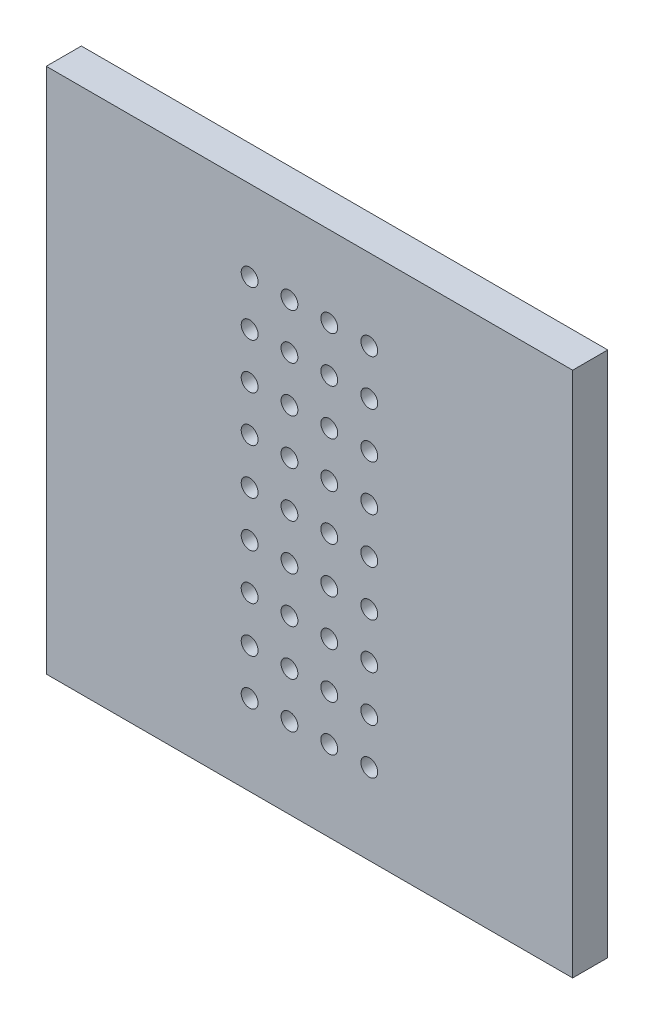
from build123d import *

# Parameters (mm, degrees)
ESQUISSE1_W            = 30
ESQUISSE1_H            = 30
BASE_PLATE_DEPTH       = 2
SKETCH_PERFORATIONS_R  = 0.48
CUT_PERFORATIONS_DEPTH = 10


with BuildPart() as part:
    # Esquisse1 → Base_Plate (new body)
    with BuildSketch(Plane.XY):
        Rectangle(ESQUISSE1_W, ESQUISSE1_H)
    extrude(amount=BASE_PLATE_DEPTH)

    # Sketch_Perforations → Cut_Perforations (cut)
    with BuildSketch(Plane.XY.offset(2)):
        with Locations((-3.41, -10.4)):
            Circle(SKETCH_PERFORATIONS_R)
        with Locations((-3.41, -7.8)):
            Circle(SKETCH_PERFORATIONS_R)
        with Locations((-3.41, -5.2)):
            Circle(SKETCH_PERFORATIONS_R)
        with Locations((-3.41, -2.6)):
            Circle(SKETCH_PERFORATIONS_R)
        with Locations((-3.41, 0)):
            Circle(SKETCH_PERFORATIONS_R)
        with Locations((-3.41, 2.6)):
            Circle(SKETCH_PERFORATIONS_R)
        with Locations((-3.41, 5.2)):
            Circle(SKETCH_PERFORATIONS_R)
        with Locations((-3.41, 7.8)):
            Circle(SKETCH_PERFORATIONS_R)
        with Locations((-3.41, 10.4)):
            Circle(SKETCH_PERFORATIONS_R)
        with Locations((-1.14, -10.4)):
            Circle(SKETCH_PERFORATIONS_R)
        with Locations((-1.14, -7.8)):
            Circle(SKETCH_PERFORATIONS_R)
        with Locations((-1.14, -5.2)):
            Circle(SKETCH_PERFORATIONS_R)
        with Locations((-1.14, -2.6)):
            Circle(SKETCH_PERFORATIONS_R)
        with Locations((-1.14, 0)):
            Circle(SKETCH_PERFORATIONS_R)
        with Locations((-1.14, 2.6)):
            Circle(SKETCH_PERFORATIONS_R)
        with Locations((-1.14, 5.2)):
            Circle(SKETCH_PERFORATIONS_R)
        with Locations((-1.14, 7.8)):
            Circle(SKETCH_PERFORATIONS_R)
        with Locations((-1.14, 10.4)):
            Circle(SKETCH_PERFORATIONS_R)
        with Locations((1.13, -10.4)):
            Circle(SKETCH_PERFORATIONS_R)
        with Locations((1.13, -7.8)):
            Circle(SKETCH_PERFORATIONS_R)
        with Locations((1.13, -5.2)):
            Circle(SKETCH_PERFORATIONS_R)
        with Locations((1.13, -2.6)):
            Circle(SKETCH_PERFORATIONS_R)
        with Locations((1.13, 0)):
            Circle(SKETCH_PERFORATIONS_R)
        with Locations((1.13, 2.6)):
            Circle(SKETCH_PERFORATIONS_R)
        with Locations((1.13, 5.2)):
            Circle(SKETCH_PERFORATIONS_R)
        with Locations((1.13, 7.8)):
            Circle(SKETCH_PERFORATIONS_R)
        with Locations((1.13, 10.4)):
            Circle(SKETCH_PERFORATIONS_R)
        with Locations((3.41, -10.4)):
            Circle(SKETCH_PERFORATIONS_R)
        with Locations((3.41, -7.8)):
            Circle(SKETCH_PERFORATIONS_R)
        with Locations((3.41, -5.2)):
            Circle(SKETCH_PERFORATIONS_R)
        with Locations((3.41, -2.6)):
            Circle(SKETCH_PERFORATIONS_R)
        with Locations((3.41, 0)):
            Circle(SKETCH_PERFORATIONS_R)
        with Locations((3.41, 2.6)):
            Circle(SKETCH_PERFORATIONS_R)
        with Locations((3.41, 5.2)):
            Circle(SKETCH_PERFORATIONS_R)
        with Locations((3.41, 7.8)):
            Circle(SKETCH_PERFORATIONS_R)
        with Locations((3.41, 10.4)):
            Circle(SKETCH_PERFORATIONS_R)
    extrude(amount=-CUT_PERFORATIONS_DEPTH, mode=Mode.SUBTRACT)


solid = part.part
